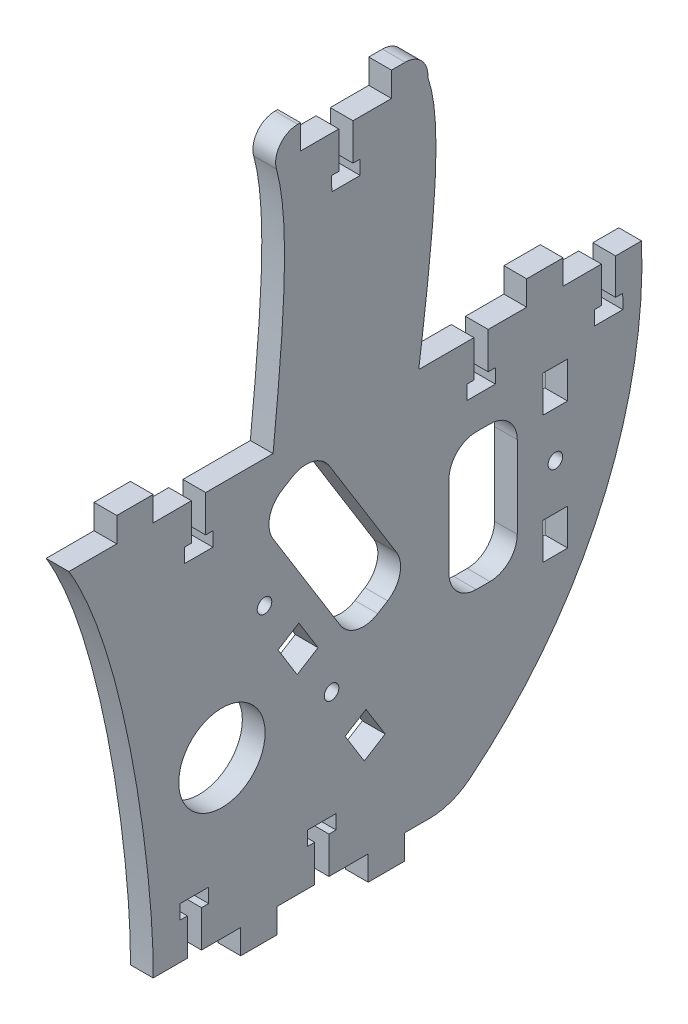
from build123d import *

# Parameters (mm, degrees)
SKETCH1_R      = 12.049005967
SKETCH1_R_2    = 2.032
EXTRUDE1_DEPTH = 6.35
FILLET3_R      = 17.78
FILLET8_R      = 6.1976
FILLET10_R     = 6.35


with BuildPart() as part:
    # Sketch1 → Extrude1 (new body)
    with BuildSketch(Plane(origin=(0, 0, 0), x_dir=(0, 0, -1), z_dir=(1, 0, 0))):
        with BuildLine():
            Line((13.365344838, 110), (0, 110))
            add(Edge.make_bspline(
                [(23.525344838, 0), (23.886396453, 21.77280911), (16.984017385, 81.503501161), (0, 110)],
                knots=[0, 0, 0, 0, 1, 1, 1, 1], degree=3))
            Line((23.525344838, 0), (33.046497245, 0))
            Line((33.046497245, 0), (33.046497245, 10.25525))
            Line((33.046497245, 10.25525), (31.062122245, 10.25525))
            Line((31.062122245, 10.25525), (31.034086884, 14.224))
            Line((31.034086884, 14.224), (38.971586884, 14.224))
            Line((38.971586884, 14.224), (38.999622245, 10.25525))
            Line((38.999622245, 10.25525), (37.015247245, 10.25525))
            Line((37.015247245, 10.25525), (37.015247245, 0))
            Line((37.015247245, 0), (47.956836884, 0))
            Line((47.956836884, 0), (47.956836884, -6.858))
            Line((47.956836884, -6.858), (58.116836884, -6.858))
            Line((58.116836884, -6.858), (58.116836884, 0))
            Line((58.116836884, 0), (68.606497245, 0))
            Line((68.606497245, 0), (68.606497245, 10.25525))
            Line((68.606497245, 10.25525), (66.622122245, 10.25525))
            Line((66.622122245, 10.25525), (66.594086884, 14.224))
            Line((66.594086884, 14.224), (74.531586884, 14.224))
            Line((74.531586884, 14.224), (74.559622245, 10.25525))
            Line((74.559622245, 10.25525), (72.575247245, 10.25525))
            Line((72.575247245, 10.25525), (72.575247245, 0))
            Line((72.575247245, 0), (83.516836884, 0))
            Line((83.516836884, 0), (83.516836884, -6.858))
            Line((83.516836884, -6.858), (93.676836884, -6.858))
            Line((93.676836884, -6.858), (93.676836884, 0))
            Line((93.676836884, 0), (106.68, 0))
            ThreePointArc((106.68, 0), (147.01715629, 48.348482811), (159.813733796, 110))
            Line((159.813733796, 110), (152.578339639, 110))
            Line((152.578339639, 110), (152.578339639, 99.96875))
            Line((152.578339639, 99.96875), (154.562714639, 99.96875))
            Line((154.562714639, 99.96875), (154.59075, 96))
            Line((154.59075, 96), (146.65325, 96))
            Line((146.65325, 96), (146.625214639, 99.96875))
            Line((146.625214639, 99.96875), (148.609589639, 99.96875))
            Line((148.609589639, 99.96875), (148.609589639, 110))
            Line((148.609589639, 110), (137.922, 110))
            Line((137.922, 110), (137.922, 116.858))
            Line((137.922, 116.858), (127.762, 116.858))
            Line((127.762, 116.858), (127.762, 110))
            Line((127.762, 110), (117.018339639, 110))
            Line((117.018339639, 110), (117.018339639, 99.74475))
            Line((117.018339639, 99.74475), (119.002714639, 99.74475))
            Line((119.002714639, 99.74475), (119.03075, 95.776))
            Line((119.03075, 95.776), (111.09325, 95.776))
            Line((111.09325, 95.776), (111.065214639, 99.74475))
            Line((111.065214639, 99.74475), (113.049589639, 99.74475))
            Line((113.049589639, 99.74475), (113.049589639, 110))
            Line((113.049589639, 110), (97.632376997, 110))
            add(Edge.make_bspline(
                [(97.632376997, 110), (102.845891428, 148.686045998), (104.019096982, 168.115161248), (100.196457803, 179.300454229)],
                knots=[0.263690297, 0.263690297, 0.263690297, 0.263690297, 1, 1, 1, 1], degree=3))
            Line((100.196457803, 179.300454229), (100.196457803, 186.158454229))
            Line((100.196457803, 186.158454229), (90.036457803, 186.158454229))
            Line((90.036457803, 186.158454229), (90.036457803, 179.300454229))
            Line((90.036457803, 179.300454229), (79.292797442, 179.300454229))
            Line((79.292797442, 179.300454229), (79.292797442, 169.045204229))
            Line((79.292797442, 169.045204229), (81.277172442, 169.045204229))
            Line((81.277172442, 169.045204229), (81.305207803, 165.076454229))
            Line((81.305207803, 165.076454229), (73.367707803, 165.076454229))
            Line((73.367707803, 165.076454229), (73.339672442, 169.045204229))
            Line((73.339672442, 169.045204229), (75.324047442, 169.045204229))
            Line((75.324047442, 169.045204229), (75.324047442, 179.300454229))
            Line((75.324047442, 179.300454229), (64.636457803, 179.300454229))
            Line((64.636457803, 179.300454229), (64.636457803, 186.158454229))
            Line((64.636457803, 186.158454229), (54.476457803, 186.158454229))
            add(Edge.make_bspline(
                [(54.476457803, 186.158454229), (63.233505027, 173.481312137), (60.112941012, 141.740656068), (56.992376997, 110)],
                knots=[0, 0, 0, 0, 1, 1, 1, 1], degree=3))
            Line((56.992376997, 110), (38.181684477, 110))
            Line((38.181684477, 110), (38.181684477, 99.74475))
            Line((38.181684477, 99.74475), (40.166059477, 99.74475))
            Line((40.166059477, 99.74475), (40.194094838, 95.776))
            Line((40.194094838, 95.776), (32.256594838, 95.776))
            Line((32.256594838, 95.776), (32.228559477, 99.74475))
            Line((32.228559477, 99.74475), (34.212934477, 99.74475))
            Line((34.212934477, 99.74475), (34.212934477, 110))
            Line((34.212934477, 110), (23.525344838, 110))
            Line((23.525344838, 110), (23.525344838, 116.858))
            Line((23.525344838, 116.858), (13.365344838, 116.858))
            Line((13.365344838, 116.858), (13.365344838, 110))
        make_face()
        Polygon((77.081007641, 31.622417606), (82.911687358, 35.23286606), (88.260499882, 26.594822035), (82.429820165, 22.984373581), align=None, mode=Mode.SUBTRACT)
        with Locations((42.714261702, 43.633986225)):
            Circle(SKETCH1_R, mode=Mode.SUBTRACT)
        with Locations((73.310331844, 44.225196864)):
            Circle(SKETCH1_R_2, mode=Mode.SUBTRACT)
        Polygon((139.194257476, 46.072756303), (132.336275936, 46.056844127), (132.312702342, 56.216816779), (139.170683882, 56.232728955), align=None, mode=Mode.SUBTRACT)
        Polygon((58.360163805, 61.855571693), (64.190843522, 65.466020147), (69.539656047, 56.827976122), (63.70897633, 53.217527668), align=None, mode=Mode.SUBTRACT)
        with BuildLine():
            ThreePointArc((106.081947056, 79.295723893), (108.313793383, 84.683877565), (113.701947056, 86.915723893))
            Line((113.701947056, 86.915723893), (117.511947056, 86.915723893))
            ThreePointArc((117.511947056, 86.915723893), (122.900100729, 84.683877565), (125.131947056, 79.295723893))
            Line((125.131947056, 79.295723893), (125.131947056, 56.435723893))
            ThreePointArc((125.131947056, 56.435723893), (122.900100729, 51.04757022), (117.511947056, 48.815723893))
            Line((117.511947056, 48.815723893), (113.701947056, 48.815723893))
            ThreePointArc((113.701947056, 48.815723893), (108.313793383, 51.04757022), (106.081947056, 56.435723893))
            Line((106.081947056, 56.435723893), (106.081947056, 79.295723893))
        make_face(mode=Mode.SUBTRACT)
        with Locations((54.589488008, 74.458350952)):
            Circle(SKETCH1_R_2, mode=Mode.SUBTRACT)
        with Locations((135.765266706, 68.924861749)):
            Circle(SKETCH1_R_2, mode=Mode.SUBTRACT)
        with BuildLine():
            ThreePointArc((56.974437356, 89.423104749), (56.03531954, 95.179092566), (59.441360982, 99.913247161))
            Line((59.441360982, 99.913247161), (62.214897914, 101.630664789))
            ThreePointArc((62.214897914, 101.630664789), (67.970885731, 102.569782605), (72.705040326, 99.163741163))
            Line((72.705040326, 99.163741163), (91.425884161, 68.930587076))
            ThreePointArc((91.425884161, 68.930587076), (92.365001978, 63.174599258), (88.958960536, 58.440444664))
            Line((88.958960536, 58.440444664), (86.185423604, 56.723027036))
            ThreePointArc((86.185423604, 56.723027036), (80.429435786, 55.783909219), (75.695281192, 59.189950661))
            Line((75.695281192, 59.189950661), (56.974437356, 89.423104749))
        make_face(mode=Mode.SUBTRACT)
        Polygon((139.170683882, 81.616994542), (132.312702342, 81.632906718), (132.336275936, 91.79287937), (139.194257476, 91.776967194), align=None, mode=Mode.SUBTRACT)
    extrude(amount=EXTRUDE1_DEPTH)

    # Fillet3
    fillet3_edges = [part.edges().sort_by_distance(p)[0] for p in [
        (3.175, 0, -106.68),
    ]]
    fillet(fillet3_edges, radius=FILLET3_R)

    # Fillet8
    fillet8_edges = [part.edges().sort_by_distance(p)[0] for p in [
        (3.175, 186.158454229, -54.476457803),
    ]]
    fillet(fillet8_edges, radius=FILLET8_R)

    # Fillet10
    fillet10_edges = [part.edges().sort_by_distance(p)[0] for p in [
        (3.175, 186.158454229, -100.196457803),
    ]]
    fillet(fillet10_edges, radius=FILLET10_R)


solid = part.part
